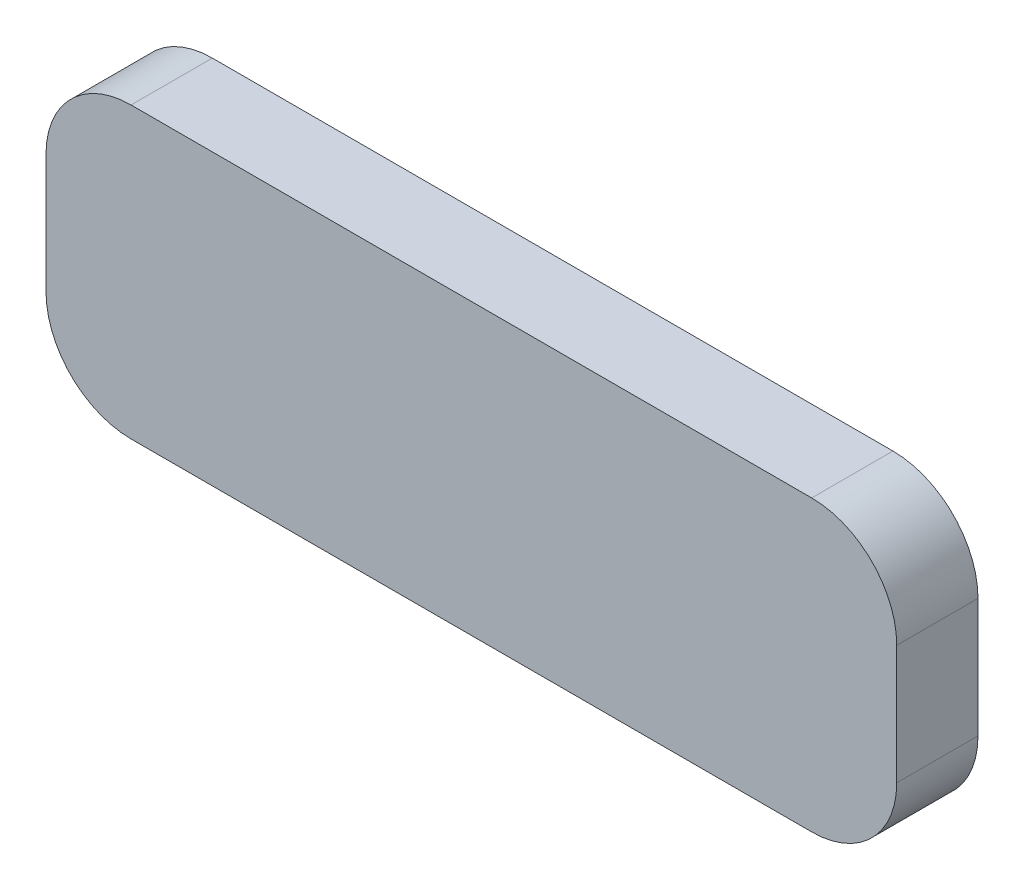
from build123d import *

# Parameters (mm, degrees)
BOSS_EXTRUDE1_DEPTH = 4.7752


with BuildPart() as part:
    # Sketch1 → Boss-Extrude1 (new body)
    with BuildSketch(Plane.XY):
        with BuildLine():
            Line((5, -4.7752), (45, -4.7752))
            ThreePointArc((45, -4.7752), (48.535533906, -3.310733906), (50, 0.2248))
            Line((50, 0.2248), (50, 7.2248))
            ThreePointArc((50, 7.2248), (48.535533906, 10.760333906), (45, 12.2248))
            Line((45, 12.2248), (5, 12.2248))
            ThreePointArc((5, 12.2248), (1.464466094, 10.760333906), (0, 7.2248))
            Line((0, 7.2248), (0, 0.2248))
            ThreePointArc((0, 0.2248), (1.464466094, -3.310733906), (5, -4.7752))
        make_face()
    extrude(amount=BOSS_EXTRUDE1_DEPTH)


solid = part.part
